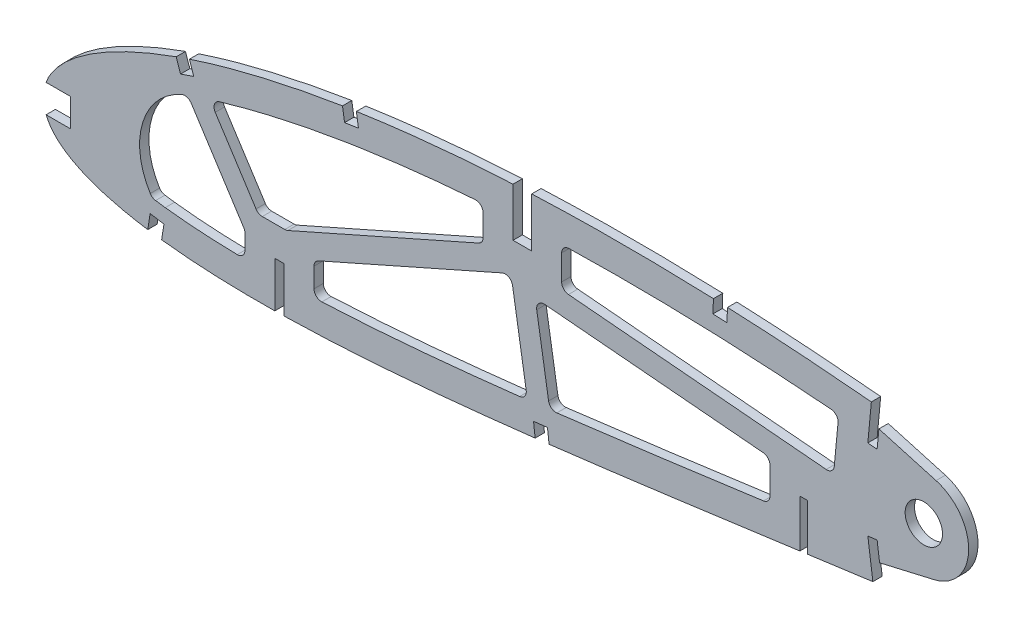
from build123d import *

# Parameters (mm, degrees)
BOSS_EXTRUDE1_DEPTH = 3.175
CUT_EXTRUDE1_DEPTH  = 7.62
SKETCH3_R           = 6.35
CUT_EXTRUDE2_DEPTH  = 7.62
CUT_EXTRUDE3_DEPTH  = 460.680430564
CUT_EXTRUDE4_DEPTH  = 320.461002544
FILLET1_R           = 2.54


with BuildPart() as part:
    # Sketch1 → Boss-Extrude1 (new body)
    with BuildSketch(Plane.XY):
        with BuildLine():
            Line((452.103130844, 0.704841059), (456.093968789, -1.676407199))
            Line((456.093968789, -1.676407199), (451.539257956, -0.704841059))
            add(Edge.make_bspline(
                [(0, 0), (0.116098484, -0.548062271), (0.348829019, -1.646705608), (0.981127511, -3.228296827), (1.817312083, -4.748664111), (2.874932324, -6.203769023), (4.146956076, -7.593213852), (5.630573928, -8.918443806), (7.324330898, -10.17874635), (9.226010202, -11.373547856), (11.332849305, -12.504116729), (13.642480166, -13.569749989), (16.152796843, -14.570114683), (18.861064307, -15.503873502), (21.763971588, -16.372448625), (24.858758771, -17.173723352), (28.141906776, -17.908817596), (31.610257831, -18.575854993), (35.260032504, -19.175513209), (39.087439203, -19.707456616), (43.088549366, -20.172017908), (47.259437594, -20.568222339), (51.595978462, -20.896922095), (56.093849686, -21.158335191), (60.748685259, -21.353290574), (65.556026339, -21.481047186), (70.511164689, -21.543596642), (75.60962225, -21.541878079), (80.846411515, -21.475431763), (86.217059019, -21.347928406), (91.716411041, -21.158560481), (97.339502767, -20.909619435), (103.081262098, -20.60361064), (108.936539298, -20.241571378), (114.900181528, -19.825106256), (120.967010704, -19.35755507), (127.131515672, -18.84008407), (133.388320155, -18.27570942), (139.73188498, -17.667256592), (146.156729407, -17.016651105), (152.657182369, -16.326953548), (159.227454029, -15.600398833), (165.861955098, -14.840863119), (172.554624992, -14.049720613), (179.299804335, -13.231488425), (186.0911476, -12.387729793), (192.922975871, -11.521694689), (199.789144556, -10.637460813), (206.683225759, -9.734927313), (213.599421065, -8.820524357), (220.53106073, -7.893498895), (227.472111233, -6.958618548), (234.416147314, -6.018789286), (241.356405409, -5.07430035), (248.28678484, -4.129065861), (255.200856388, -3.185680808), (262.091847615, -2.244231265), (268.953524037, -1.309396646), (275.778976202, -0.38106275), (282.561910312, 0.538888344), (289.295826346, 1.447710664), (295.974371147, 2.344257157), (302.590655451, 3.227960607), (309.138022785, 4.099152889), (315.511866205, 4.931391047), (321.69553077, 5.768992271), (327.709854245, 6.4556395), (333.649291775, 7.04171769), (339.520012945, 7.522220911), (345.31496828, 7.904062197), (351.027518107, 8.189969928), (356.650854245, 8.383935735), (362.17787359, 8.491713952), (367.601672755, 8.516039607), (372.914848341, 8.464670411), (378.110490176, 8.34174704), (383.181346836, 8.152787103), (388.120344083, 7.904165623), (392.920466429, 7.60266025), (397.574507523, 7.252718477), (402.075982121, 6.8625098), (406.417945063, 6.437746476), (410.593729281, 5.983281443), (414.597241701, 5.508637621), (418.422074216, 5.016940024), (422.062473684, 4.516268978), (425.512580015, 4.011698392), (428.766929364, 3.509669922), (431.820408455, 3.014973074), (434.668085107, 2.534173613), (437.305498365, 2.071763811), (439.728071725, 1.632259415), (441.932444373, 1.221205742), (443.914262697, 0.840644737), (445.670876088, 0.49684807), (447.199018295, 0.19133282), (448.496449148, -0.071596745), (449.560902928, -0.290902855), (450.390762879, -0.462985534), (450.984389878, -0.5881196), (451.34114184, -0.662580877), (451.499651332, -0.696392563), (451.539257956, -0.704841059)],
                knots=[0, 0, 0, 0, 0.003638255, 0.007293231, 0.011028136, 0.014901081, 0.018963272, 0.023258475, 0.027820626, 0.032679082, 0.03785316, 0.043361875, 0.049214679, 0.055422346, 0.061988786, 0.068918036, 0.076211157, 0.083868392, 0.091887411, 0.100265912, 0.108999867, 0.118084529, 0.127514843, 0.13728527, 0.147387917, 0.157816481, 0.168563473, 0.179619128, 0.190977373, 0.202626974, 0.214560478, 0.226767249, 0.239236417, 0.251959004, 0.264923894, 0.278119703, 0.291536035, 0.30516028, 0.318980685, 0.332985499, 0.34716279, 0.361498603, 0.375980747, 0.390597192, 0.405332593, 0.420174823, 0.435109533, 0.450124276, 0.465203068, 0.480333154, 0.495500583, 0.510689775, 0.525887334, 0.541078314, 0.556247233, 0.571381785, 0.58646604, 0.601484515, 0.616424329, 0.631269423, 0.646006524, 0.660620684, 0.675098187, 0.689422858, 0.703581825, 0.716907563, 0.730009274, 0.742952128, 0.755725557, 0.768319951, 0.780724337, 0.792926528, 0.804916041, 0.816679084, 0.828203525, 0.8394749, 0.850481359, 0.861207697, 0.871639326, 0.881763414, 0.891563605, 0.901027365, 0.910138977, 0.918883977, 0.927249278, 0.935221104, 0.942784739, 0.949928188, 0.956638465, 0.962904203, 0.968712288, 0.974054485, 0.978918432, 0.983297219, 0.987180246, 0.990560674, 0.993433357, 0.995790626, 0.997629588, 0.998945816, 0.999736592, 1, 1, 1, 1], degree=3))
            add(Edge.make_bspline(
                [(452.103130844, 0.704841059), (452.068496813, 0.726236426), (451.930095213, 0.811734792), (451.618251437, 1.003015711), (451.098966561, 1.321603382), (450.372013154, 1.765285304), (449.437955605, 2.332883088), (448.296324058, 3.020422222), (446.947831268, 3.825669225), (445.392803438, 4.744815234), (443.631400049, 5.773556989), (441.66429165, 6.907726386), (439.491649667, 8.140902925), (437.114315549, 9.468047233), (434.533105048, 10.882848063), (431.748506266, 12.378914822), (428.761516485, 13.948638114), (425.573282246, 15.58526602), (422.184384898, 17.279761053), (418.59642206, 19.025070833), (414.810589229, 20.812493246), (410.828178709, 22.632492429), (406.65147817, 24.477648573), (402.281642423, 26.336490908), (397.721161703, 28.200965635), (392.971977542, 30.06046153), (388.036901986, 31.906510246), (382.917838926, 33.727152381), (377.618614974, 35.514431666), (372.141800823, 37.256737501), (366.491313143, 38.944607324), (360.670434952, 40.56709799), (354.684018662, 42.115888344), (348.535860801, 43.579699531), (342.231172339, 44.948733274), (335.774964791, 46.214747245), (329.172652762, 47.36510198), (322.442531978, 48.398900537), (315.692888447, 49.25884604), (308.957131835, 50.102255317), (302.231406377, 50.894561333), (295.423478513, 51.653303868), (288.539897863, 52.374211064), (281.587492313, 53.055028822), (274.573300246, 53.692818583), (267.504610588, 54.285710178), (260.388263375, 54.830343915), (253.231762389, 55.325880728), (246.04218283, 55.767964282), (238.827182474, 56.156262652), (231.594085468, 56.488067665), (224.350419046, 56.761093174), (217.103874943, 56.973690929), (209.861975326, 57.123824182), (202.632561324, 57.210549036), (195.423152651, 57.231495803), (188.241586793, 57.186289729), (181.095384018, 57.073378669), (173.992389816, 56.89121691), (166.940134698, 56.63946441), (159.9462446, 56.318230463), (153.018377106, 55.924824851), (146.164047723, 55.461754745), (139.39088931, 54.92707481), (132.706343647, 54.320642895), (126.117416199, 53.644986873), (119.631442696, 52.898268934), (113.255374135, 52.082613865), (106.996184656, 51.199620764), (100.86089724, 50.248808671), (94.856084142, 49.232924024), (88.98822628, 48.153006108), (83.263531815, 47.012221039), (77.688233433, 45.810866329), (72.268232878, 44.552545746), (67.009162956, 43.23945158), (61.916677035, 41.873987713), (56.99593741, 40.459430694), (52.251920045, 38.998989643), (47.690155321, 37.494269359), (43.314090924, 35.950975056), (39.129102409, 34.370202293), (35.138395613, 32.756820932), (31.346647327, 31.113033952), (27.756690145, 29.443852436), (24.372587071, 27.751176724), (21.196749975, 26.039749097), (18.232367129, 24.312193837), (15.482292083, 22.571719722), (12.9476807, 20.82274152), (10.632027491, 19.066357057), (8.536127933, 17.307004609), (6.661308341, 15.547363257), (5.010248609, 13.788645116), (3.582889331, 12.033947283), (2.381101114, 10.284659424), (1.405092396, 8.542436815), (0.657070826, 6.808544998), (0.13629461, 5.083959089), (-0.148774805, 3.371224525), (-0.21973029, 1.668968236), (-0.073133992, 0.555491501), (0, 0)],
                knots=[0, 0, 0, 0, 0.00025409, 0.001015373, 0.002283359, 0.004056577, 0.006330982, 0.009105274, 0.012374489, 0.016134023, 0.02037966, 0.025105976, 0.030306237, 0.035972206, 0.042099522, 0.048678064, 0.055701664, 0.063160184, 0.071045824, 0.079349826, 0.08806291, 0.097175756, 0.106678112, 0.116561573, 0.126814275, 0.137428301, 0.148393618, 0.15969976, 0.171338126, 0.183297699, 0.195569604, 0.208143556, 0.221011593, 0.234161831, 0.24758745, 0.261276822, 0.27522271, 0.289414144, 0.303771199, 0.317689227, 0.331784111, 0.346039677, 0.36044387, 0.37498272, 0.389640454, 0.404403316, 0.419256601, 0.434186749, 0.449177265, 0.464214782, 0.479284009, 0.49436974, 0.509457833, 0.524532346, 0.53957932, 0.554582984, 0.569529546, 0.584403417, 0.599190992, 0.613876838, 0.628447475, 0.642888675, 0.657186054, 0.671325546, 0.685294014, 0.699078147, 0.712665095, 0.726042645, 0.739197713, 0.752117586, 0.764792042, 0.777208152, 0.789355685, 0.80122396, 0.812803686, 0.824082909, 0.835054602, 0.845709571, 0.856037853, 0.866033834, 0.875688843, 0.884997719, 0.893953426, 0.902552897, 0.910789386, 0.918660734, 0.926166253, 0.933302626, 0.94007122, 0.94647478, 0.952517526, 0.958204819, 0.963546652, 0.9685566, 0.973249913, 0.977651041, 0.981787043, 0.985694226, 0.989415109, 0.993001157, 0.996508416, 1, 1, 1, 1], degree=3))
        make_face()
    extrude(amount=BOSS_EXTRUDE1_DEPTH)

    # Sketch2 → Cut-Extrude1 (cut)
    with BuildSketch(Plane(origin=(0, 0, 0), x_dir=(-1, 0, 0), z_dir=(0, 0, -1))):
        Polygon((-81.649081478, -6.010725061), (-78.474081478, -6.010725061), (-78.474081478, -20.922752068), (-78.474081478, -21.704811205), (-81.649081478, -22.486870342), (-81.649081478, -20.922752068), align=None)
        Polygon((-259.449081478, 13.22073836), (-259.449081478, -2.652607086), (-259.449081478, -5.069769756), (-256.909081478, -3.861188421), (-256.909081478, -2.652607086), (-256.909081478, 13.22073836), align=None)
        Polygon((-165.786581478, 56.593547672), (-165.786581478, 39.762876916), (-159.436581478, 39.762876916), (-159.436581478, 56.593547672), (-159.436581478, 57.557196897), (-165.786581478, 58.520846121), align=None)
    extrude(amount=-CUT_EXTRUDE1_DEPTH, mode=Mode.SUBTRACT)

    # Sketch3 → Cut-Extrude2 (cut)
    with BuildSketch(Plane(origin=(0, 0, 0), x_dir=(-1, 0, 0), z_dir=(0, 0, -1))):
        with Locations((-299.038447077, 26.255421435)):
            Circle(SKETCH3_R)
    extrude(amount=-CUT_EXTRUDE2_DEPTH, mode=Mode.SUBTRACT)

    # Sketch4 → Cut-Extrude3 (cut, through all)
    with BuildSketch(Plane.XY.offset(3.175)):
        with BuildLine():
            Line((9.076666365, 6.890948983), (0.724721742, 6.890948983))
            add(Edge.make_bspline(
                [(0.724721742, 6.890948983), (0.709496177, 6.850122056), (0.488246053, 6.249470262), (0.13629461, 5.083959089), (-0.148774805, 3.371224525), (-0.21973029, 1.668968236), (-0.073133992, 0.555491501), (0, 0)],
                knots=[0.985422425, 0.985422425, 0.985422425, 0.985422425, 0.985694226, 0.989415109, 0.993001157, 0.996508416, 1, 1, 1, 1], degree=3))
            add(Edge.make_bspline(
                [(0, 0), (0.116098484, -0.548062271), (0.305939132, -1.444236737), (0.619159788, -2.305351823), (0.755399229, -2.634051017)],
                knots=[0, 0, 0, 0, 0.003638255, 0.005949162, 0.005949162, 0.005949162, 0.005949162], degree=3))
            Line((0.755399229, -2.634051017), (9.076666365, -2.634051017))
            Line((9.076666365, -2.634051017), (9.076666365, 6.890948983))
        make_face()
        with BuildLine():
            Line((50.94528914, 33.718880333), (49.457984223, 38.072533111))
            add(Edge.make_bspline(
                [(49.457984223, 38.072533111), (48.852375707, 37.871291192), (47.347795701, 37.364546546), (45.848492359, 36.842318766), (44.953969582, 36.524088968)],
                knots=[0.862050759, 0.862050759, 0.862050759, 0.862050759, 0.866033834, 0.871959688, 0.871959688, 0.871959688, 0.871959688], degree=3))
            Line((44.953969582, 36.524088968), (46.438686443, 32.179166464))
            Line((46.438686443, 32.179166464), (50.94528914, 33.718880333))
        make_face()
        with BuildLine():
            add(Edge.make_bspline(
                [(35.310795336, -19.167418321), (36.550140988, -19.354805569), (38.11863538, -19.57232394), (39.689829469, -19.768564004), (40.017366507, -19.808559412)],
                knots=[0.092113445, 0.092113445, 0.092113445, 0.092113445, 0.100265912, 0.102412087, 0.102412087, 0.102412087, 0.102412087], degree=3))
            Line((40.017366507, -19.808559412), (40.056230108, -19.559199628))
            Line((40.056230108, -19.559199628), (40.810392071, -14.791064015))
            Line((40.810392071, -14.791064015), (36.113723666, -14.052515981))
            Line((36.113723666, -14.052515981), (35.373024236, -18.771000939))
            Line((35.373024236, -18.771000939), (35.310795336, -19.167418321))
        make_face()
        with BuildLine():
            Line((39.567645247, -22.694097363), (40.017366507, -19.808559412))
            add(Edge.make_bspline(
                [(35.310795336, -19.167418321), (36.550140988, -19.354805569), (38.11863538, -19.57232394), (39.689829469, -19.768564004), (40.017366507, -19.808559412)],
                knots=[0.092113445, 0.092113445, 0.092113445, 0.092113445, 0.100265912, 0.102412087, 0.102412087, 0.102412087, 0.102412087], degree=3))
            Line((35.310795336, -19.167418321), (34.872872851, -21.957120289))
            Line((34.872872851, -21.957120289), (39.567645247, -22.694097363))
        make_face()
        with BuildLine():
            Line((106.90066319, 46.481463728), (106.209861612, 51.068186439))
            add(Edge.make_bspline(
                [(106.209861612, 51.068186439), (104.629351245, 50.831477167), (103.050077247, 50.586505601), (101.472164136, 50.333054309)],
                knots=[0.740777655, 0.740777655, 0.740777655, 0.740777655, 0.750752382, 0.750752382, 0.750752382, 0.750752382], degree=3))
            Line((101.472164136, 50.333054309), (102.191303266, 45.7721599))
            Line((102.191303266, 45.7721599), (106.90066319, 46.481463728))
        make_face()
        with BuildLine():
            add(Edge.make_bspline(
                [(166.948991926, -14.709918965), (168.528216327, -14.525231657), (170.10720639, -14.338540702), (171.685988187, -14.15010551)],
                knots=[0.378399329, 0.378399329, 0.378399329, 0.378399329, 0.388741043, 0.388741043, 0.388741043, 0.388741043], degree=3))
            Line((171.685988187, -14.15010551), (171.13396989, -9.48059682))
            Line((171.13396989, -9.48059682), (166.404404763, -10.039712392))
            Line((166.404404763, -10.039712392), (166.948991926, -14.709918965))
        make_face()
        with BuildLine():
            Line((232.119167537, 51.839052458), (232.321761642, 56.447492051))
            add(Edge.make_bspline(
                [(232.321761642, 56.447492051), (232.079950316, 56.457793824), (230.485264408, 56.525079676), (228.890398482, 56.588062732), (227.537258876, 56.638361271)],
                knots=[0.477773375, 0.477773375, 0.477773375, 0.477773375, 0.479284009, 0.48773546, 0.48773546, 0.48773546, 0.48773546], degree=3))
            Line((227.537258876, 56.638361271), (227.36106217, 52.037340067))
            Line((227.36106217, 52.037340067), (232.119167537, 51.839052458))
        make_face()
        with BuildLine():
            Line((280.002959876, 40.404001741), (283.163447077, 40.103220767))
            Line((283.163447077, 40.103220767), (283.772153107, 46.420883565))
            Line((283.772153107, 46.420883565), (284.380859136, 52.738546364))
            Line((284.380859136, 52.738546364), (284.384742546, 52.778851653))
            add(Edge.make_bspline(
                [(284.384742546, 52.778851653), (283.458514825, 52.868893345), (282.400140093, 52.970319768), (281.341607713, 53.07007766), (281.209561744, 53.0824957)],
                knots=[0.369174414, 0.369174414, 0.369174414, 0.369174414, 0.37498272, 0.375810522, 0.375810522, 0.375810522, 0.375810522], degree=3))
            Line((281.209561744, 53.0824957), (281.206083771, 53.045950544))
            Line((281.206083771, 53.045950544), (280.002959876, 40.404001741))
        make_face()
        with BuildLine():
            add(Edge.make_bspline(
                [(284.384742546, 52.778851653), (283.458514825, 52.868893345), (282.400140093, 52.970319768), (281.341607713, 53.07007766), (281.209561744, 53.0824957)],
                knots=[0.369174414, 0.369174414, 0.369174414, 0.369174414, 0.37498272, 0.375810522, 0.375810522, 0.375810522, 0.375810522], degree=3))
            Line((284.384742546, 52.778851653), (284.770272262, 56.780203084))
            Line((284.770272262, 56.780203084), (281.590271339, 57.082841163))
            Line((281.590271339, 57.082841163), (281.209561744, 53.0824957))
        make_face()
        with BuildLine():
            Line((284.380859136, 52.738546364), (283.772153107, 46.420883565))
            Line((283.772153107, 46.420883565), (303.192982236, 40.918212356))
            ThreePointArc((303.192982236, 40.918212356), (311.195188331, 35.446245233), (314.278447077, 26.255421435))
            ThreePointArc((314.278447077, 26.255421435), (310.969793045, 16.773829618), (302.480470254, 11.409207222))
            Line((302.480470254, 11.409207222), (284.012930322, 7.127597139))
            Line((284.012930322, 7.127597139), (284.860476862, 0.848860649))
            add(Edge.make_bspline(
                [(284.860476862, 0.848860649), (286.34516108, 1.049390117), (290.056592049, 1.549837975), (295.974371147, 2.344257157), (302.590655451, 3.227960607), (309.138022785, 4.099152889), (315.511866205, 4.931391047), (321.69553077, 5.768992271), (327.709854245, 6.4556395), (333.649291775, 7.04171769), (339.520012945, 7.522220911), (345.31496828, 7.904062197), (351.027518107, 8.189969928), (356.650854245, 8.383935735), (362.17787359, 8.491713952), (367.601672755, 8.516039607), (372.914848341, 8.464670411), (378.110490176, 8.34174704), (383.181346836, 8.152787103), (388.120344083, 7.904165623), (392.920466429, 7.60266025), (397.574507523, 7.252718477), (402.075982121, 6.8625098), (406.417945063, 6.437746476), (410.593729281, 5.983281443), (414.597241701, 5.508637621), (418.422074216, 5.016940024), (422.062473684, 4.516268978), (425.512580015, 4.011698392), (428.766929364, 3.509669922), (431.820408455, 3.014973074), (434.668085107, 2.534173613), (437.305498365, 2.071763811), (439.728071725, 1.632259415), (441.932444373, 1.221205742), (443.914262697, 0.840644737), (445.670876088, 0.49684807), (447.199018295, 0.19133282), (448.496449148, -0.071596745), (449.560902928, -0.290902855), (450.390762879, -0.462985534), (450.984389878, -0.5881196), (451.34114184, -0.662580877), (451.499651332, -0.696392563), (451.539257956, -0.704841059)],
                knots=[0.63626204, 0.63626204, 0.63626204, 0.63626204, 0.646006524, 0.660620684, 0.675098187, 0.689422858, 0.703581825, 0.716907563, 0.730009274, 0.742952128, 0.755725557, 0.768319951, 0.780724337, 0.792926528, 0.804916041, 0.816679084, 0.828203525, 0.8394749, 0.850481359, 0.861207697, 0.871639326, 0.881763414, 0.891563605, 0.901027365, 0.910138977, 0.918883977, 0.927249278, 0.935221104, 0.942784739, 0.949928188, 0.956638465, 0.962904203, 0.968712288, 0.974054485, 0.978918432, 0.983297219, 0.987180246, 0.990560674, 0.993433357, 0.995790626, 0.997629588, 0.998945816, 0.999736592, 1, 1, 1, 1], degree=3))
            Line((451.539257956, -0.704841059), (456.093968789, -1.676407199))
            Line((456.093968789, -1.676407199), (452.103130844, 0.704841059))
            add(Edge.make_bspline(
                [(452.103130844, 0.704841059), (452.068496813, 0.726236426), (451.930095213, 0.811734792), (451.618251437, 1.003015711), (451.098966561, 1.321603382), (450.372013154, 1.765285304), (449.437955605, 2.332883088), (448.296324058, 3.020422222), (446.947831268, 3.825669225), (445.392803438, 4.744815234), (443.631400049, 5.773556989), (441.66429165, 6.907726386), (439.491649667, 8.140902925), (437.114315549, 9.468047233), (434.533105048, 10.882848063), (431.748506266, 12.378914822), (428.761516485, 13.948638114), (425.573282246, 15.58526602), (422.184384898, 17.279761053), (418.59642206, 19.025070833), (414.810589229, 20.812493246), (410.828178709, 22.632492429), (406.65147817, 24.477648573), (402.281642423, 26.336490908), (397.721161703, 28.200965635), (392.971977542, 30.06046153), (388.036901986, 31.906510246), (382.917838926, 33.727152381), (377.618614974, 35.514431666), (372.141800823, 37.256737501), (366.491313143, 38.944607324), (360.670434952, 40.56709799), (354.684018662, 42.115888344), (348.535860801, 43.579699531), (342.231172339, 44.948733274), (335.774964791, 46.214747245), (329.172652762, 47.36510198), (322.442531978, 48.398900537), (315.692888447, 49.25884604), (308.957131835, 50.102255317), (302.231406377, 50.894561333), (295.423478513, 51.653303868), (289.603246246, 52.262848164), (286.052736483, 52.616099696), (284.798474131, 52.738546364)],
                knots=[0, 0, 0, 0, 0.00025409, 0.001015373, 0.002283359, 0.004056577, 0.006330982, 0.009105274, 0.012374489, 0.016134023, 0.02037966, 0.025105976, 0.030306237, 0.035972206, 0.042099522, 0.048678064, 0.055701664, 0.063160184, 0.071045824, 0.079349826, 0.08806291, 0.097175756, 0.106678112, 0.116561573, 0.126814275, 0.137428301, 0.148393618, 0.15969976, 0.171338126, 0.183297699, 0.195569604, 0.208143556, 0.221011593, 0.234161831, 0.24758745, 0.261276822, 0.27522271, 0.289414144, 0.303771199, 0.317689227, 0.331784111, 0.346039677, 0.36044387, 0.368309569, 0.368309569, 0.368309569, 0.368309569], degree=3))
            Line((284.798474131, 52.738546364), (284.380859136, 52.738546364))
        make_face()
        with BuildLine():
            Line((284.860476862, 0.848860649), (284.012930322, 7.127597139))
            Line((284.012930322, 7.127597139), (283.163447077, 13.420680993))
            Line((283.163447077, 13.420680993), (280.017033521, 12.995599475))
            Line((280.017033521, 12.995599475), (281.715516034, 0.4235911))
            add(Edge.make_bspline(
                [(281.715516034, 0.4235911), (282.003163555, 0.462531675), (283.051468053, 0.604404862), (284.099794103, 0.746118727), (284.860476862, 0.848860649)],
                knots=[0.629381417, 0.629381417, 0.629381417, 0.629381417, 0.631269423, 0.63626204, 0.63626204, 0.63626204, 0.63626204], degree=3))
        make_face()
        with BuildLine():
            Line((284.862413567, 0.834513285), (284.860476862, 0.848860649))
            add(Edge.make_bspline(
                [(281.715516034, 0.4235911), (282.003163555, 0.462531675), (283.051468053, 0.604404862), (284.099794103, 0.746118727), (284.860476862, 0.848860649)],
                knots=[0.629381417, 0.629381417, 0.629381417, 0.629381417, 0.631269423, 0.63626204, 0.63626204, 0.63626204, 0.63626204], degree=3))
            Line((281.715516034, 0.4235911), (281.717359592, 0.40994525))
            Line((281.717359592, 0.40994525), (282.089214043, -2.34248654))
            Line((282.089214043, -2.34248654), (285.235627599, -1.917405022))
            Line((285.235627599, -1.917405022), (284.862413567, 0.834513285))
        make_face()
        with BuildLine():
            Line((466.088227074, 52.738546364), (284.798474131, 52.738546364))
            add(Edge.make_bspline(
                [(452.103130844, 0.704841059), (452.068496813, 0.726236426), (451.930095213, 0.811734792), (451.618251437, 1.003015711), (451.098966561, 1.321603382), (450.372013154, 1.765285304), (449.437955605, 2.332883088), (448.296324058, 3.020422222), (446.947831268, 3.825669225), (445.392803438, 4.744815234), (443.631400049, 5.773556989), (441.66429165, 6.907726386), (439.491649667, 8.140902925), (437.114315549, 9.468047233), (434.533105048, 10.882848063), (431.748506266, 12.378914822), (428.761516485, 13.948638114), (425.573282246, 15.58526602), (422.184384898, 17.279761053), (418.59642206, 19.025070833), (414.810589229, 20.812493246), (410.828178709, 22.632492429), (406.65147817, 24.477648573), (402.281642423, 26.336490908), (397.721161703, 28.200965635), (392.971977542, 30.06046153), (388.036901986, 31.906510246), (382.917838926, 33.727152381), (377.618614974, 35.514431666), (372.141800823, 37.256737501), (366.491313143, 38.944607324), (360.670434952, 40.56709799), (354.684018662, 42.115888344), (348.535860801, 43.579699531), (342.231172339, 44.948733274), (335.774964791, 46.214747245), (329.172652762, 47.36510198), (322.442531978, 48.398900537), (315.692888447, 49.25884604), (308.957131835, 50.102255317), (302.231406377, 50.894561333), (295.423478513, 51.653303868), (289.603246246, 52.262848164), (286.052736483, 52.616099696), (284.798474131, 52.738546364)],
                knots=[0, 0, 0, 0, 0.00025409, 0.001015373, 0.002283359, 0.004056577, 0.006330982, 0.009105274, 0.012374489, 0.016134023, 0.02037966, 0.025105976, 0.030306237, 0.035972206, 0.042099522, 0.048678064, 0.055701664, 0.063160184, 0.071045824, 0.079349826, 0.08806291, 0.097175756, 0.106678112, 0.116561573, 0.126814275, 0.137428301, 0.148393618, 0.15969976, 0.171338126, 0.183297699, 0.195569604, 0.208143556, 0.221011593, 0.234161831, 0.24758745, 0.261276822, 0.27522271, 0.289414144, 0.303771199, 0.317689227, 0.331784111, 0.346039677, 0.36044387, 0.368309569, 0.368309569, 0.368309569, 0.368309569], degree=3))
            Line((452.103130844, 0.704841059), (456.093968789, -1.676407199))
            Line((456.093968789, -1.676407199), (451.539257956, -0.704841059))
            add(Edge.make_bspline(
                [(284.860476862, 0.848860649), (286.34516108, 1.049390117), (290.056592049, 1.549837975), (295.974371147, 2.344257157), (302.590655451, 3.227960607), (309.138022785, 4.099152889), (315.511866205, 4.931391047), (321.69553077, 5.768992271), (327.709854245, 6.4556395), (333.649291775, 7.04171769), (339.520012945, 7.522220911), (345.31496828, 7.904062197), (351.027518107, 8.189969928), (356.650854245, 8.383935735), (362.17787359, 8.491713952), (367.601672755, 8.516039607), (372.914848341, 8.464670411), (378.110490176, 8.34174704), (383.181346836, 8.152787103), (388.120344083, 7.904165623), (392.920466429, 7.60266025), (397.574507523, 7.252718477), (402.075982121, 6.8625098), (406.417945063, 6.437746476), (410.593729281, 5.983281443), (414.597241701, 5.508637621), (418.422074216, 5.016940024), (422.062473684, 4.516268978), (425.512580015, 4.011698392), (428.766929364, 3.509669922), (431.820408455, 3.014973074), (434.668085107, 2.534173613), (437.305498365, 2.071763811), (439.728071725, 1.632259415), (441.932444373, 1.221205742), (443.914262697, 0.840644737), (445.670876088, 0.49684807), (447.199018295, 0.19133282), (448.496449148, -0.071596745), (449.560902928, -0.290902855), (450.390762879, -0.462985534), (450.984389878, -0.5881196), (451.34114184, -0.662580877), (451.499651332, -0.696392563), (451.539257956, -0.704841059)],
                knots=[0.63626204, 0.63626204, 0.63626204, 0.63626204, 0.646006524, 0.660620684, 0.675098187, 0.689422858, 0.703581825, 0.716907563, 0.730009274, 0.742952128, 0.755725557, 0.768319951, 0.780724337, 0.792926528, 0.804916041, 0.816679084, 0.828203525, 0.8394749, 0.850481359, 0.861207697, 0.871639326, 0.881763414, 0.891563605, 0.901027365, 0.910138977, 0.918883977, 0.927249278, 0.935221104, 0.942784739, 0.949928188, 0.956638465, 0.962904203, 0.968712288, 0.974054485, 0.978918432, 0.983297219, 0.987180246, 0.990560674, 0.993433357, 0.995790626, 0.997629588, 0.998945816, 0.999736592, 1, 1, 1, 1], degree=3))
            Line((284.860476862, 0.848860649), (284.862413567, 0.834513285))
            Line((284.862413567, 0.834513285), (466.088227074, -18.771000939))
            Line((466.088227074, -18.771000939), (466.088227074, 52.738546364))
        make_face()
    extrude(amount=-CUT_EXTRUDE3_DEPTH, mode=Mode.SUBTRACT)


with BuildPart() as body_2:
    # of the pieces the cut leaves, the one that is kept (cut_extrude3_keep)
    add(part.part.solids().sort_by_distance((232.321761642, 56.447492051, 0))[0])

    # Sketch5 → Cut-Extrude4 (cut, through all)
    with BuildSketch(Plane.XY.offset(3.175)):
        with BuildLine():
            ThreePointArc((48.359351671, 26.951786589), (33.662203419, 11.770011742), (36.829708633, -9.121598175))
            Line((36.829708633, -9.121598175), (41.248852551, -9.723469322))
            add(Edge.make_bspline(
                [(41.248852551, -9.723469322), (42.758212792, -9.907776656), (45.773395172, -10.235170642), (51.885654424, -10.756253149), (59.392149246, -11.170006324), (65.403526556, -11.316703139), (68.314081478, -11.35226521)],
                knots=[0.102412087, 0.102412087, 0.102412087, 0.102412087, 0.112851931, 0.123291776, 0.144171465, 0.163633402, 0.163633402, 0.163633402, 0.163633402], degree=3))
            Line((68.314081478, -11.35226521), (68.314081478, -2.882836135))
            Line((68.314081478, -2.882836135), (48.95119544, 27.155252438))
            Line((48.95119544, 27.155252438), (48.359351671, 26.951786589))
        make_face()
        with BuildLine():
            add(Edge.make_bspline(
                [(103.083454258, 40.301636456), (98.788403433, 39.611746642), (90.207213091, 38.101001537), (77.48510802, 35.41602737), (66.200354481, 32.571445305), (59.244941197, 30.530333734), (56.413940314, 29.642347547)],
                knots=[0.750752382, 0.750752382, 0.750752382, 0.750752382, 0.778576976, 0.80640157, 0.834226165, 0.853510778, 0.853510778, 0.853510778, 0.853510778], degree=3))
            Line((56.413940314, 29.642347547), (72.847058502, 4.149274939))
            Line((72.847058502, 4.149274939), (82.401104828, 4.149274939))
            Line((82.401104828, 4.149274939), (149.276581478, 33.769873793))
            Line((149.276581478, 33.769873793), (149.276581478, 45.48497375))
            add(Edge.make_bspline(
                [(149.276581478, 45.48497375), (148.461117807, 45.428450057), (143.271542371, 45.058169004), (133.728966045, 44.251429069), (120.679613621, 42.834488458), (112.032064191, 41.666849619), (107.714716991, 41.020250816)],
                knots=[0.652108864, 0.652108864, 0.652108864, 0.652108864, 0.657294996, 0.685122549, 0.712950102, 0.740777655, 0.740777655, 0.740777655, 0.740777655], degree=3))
            Line((107.714716991, 41.020250816), (103.083454258, 40.301636456))
        make_face()
        with BuildLine():
            Line((91.809081478, -0.017721939), (91.809081478, -10.977698198))
            add(Edge.make_bspline(
                [(91.809081478, -10.977698198), (91.850327892, -10.976039425), (95.390285769, -10.833286487), (105.951840754, -10.308151251), (123.515780864, -9.024316581), (144.151759364, -7.057111175), (157.773900506, -5.548051388), (164.337760971, -4.785503394)],
                knots=[0.215739949, 0.215739949, 0.215739949, 0.215739949, 0.216013438, 0.239211423, 0.285607391, 0.33200336, 0.375255674, 0.375255674, 0.375255674, 0.375255674], degree=3))
            Line((164.337760971, -4.785503394), (159.274675479, 26.383054007))
            ThreePointArc((159.274675479, 26.383054007), (157.977256776, 28.209213241), (155.738900793, 28.298181403))
            Line((155.738900793, 28.298181403), (91.809081478, -0.017721939))
        make_face()
        with BuildLine():
            Line((166.964589936, 26.567532329), (171.912257584, -3.890508193))
            add(Edge.make_bspline(
                [(171.912257584, -3.890508193), (172.031456971, -3.87620172), (178.634640162, -3.083129685), (192.315737028, -1.376017631), (212.977606558, 1.33427113), (231.319479133, 3.811506342), (242.581976085, 5.346312296), (246.749081478, 5.914913989)],
                knots=[0.391878822, 0.391878822, 0.391878822, 0.391878822, 0.392663266, 0.435331542, 0.48192204, 0.528512539, 0.555874043, 0.555874043, 0.555874043, 0.555874043], degree=3))
            Line((246.749081478, 5.914913989), (246.749081478, 19.556054472))
            Line((246.749081478, 19.556054472), (166.964589936, 26.567532329))
        make_face()
        with BuildLine():
            Line((175.946581478, 46.772554587), (175.946581478, 33.427560804))
            Line((175.946581478, 33.427560804), (268.36021076, 25.306231673))
            Line((268.36021076, 25.306231673), (270.12671756, 43.867984628))
            add(Edge.make_bspline(
                [(270.12671756, 43.867984628), (269.4767603, 43.922421238), (264.798006642, 44.309607109), (256.087087446, 44.967519612), (243.99082279, 45.725542729), (235.924202525, 46.124803088), (231.889312262, 46.296699593)],
                knots=[0.397188572, 0.397188572, 0.397188572, 0.397188572, 0.401301235, 0.426791948, 0.452282662, 0.477773375, 0.477773375, 0.477773375, 0.477773375], degree=3))
            Line((231.889312262, 46.296699593), (227.159854742, 46.485373232))
            add(Edge.make_bspline(
                [(227.159854742, 46.485373232), (222.077474167, 46.674294108), (211.906455154, 46.962763366), (196.660669325, 47.11161023), (184.673133046, 46.99252014), (177.773582226, 46.824267278), (175.946581478, 46.772554587)],
                knots=[0.48773546, 0.48773546, 0.48773546, 0.48773546, 0.519861968, 0.551988475, 0.584114983, 0.595689911, 0.595689911, 0.595689911, 0.595689911], degree=3))
        make_face()
    extrude(amount=-CUT_EXTRUDE4_DEPTH, mode=Mode.SUBTRACT)

    # Fillet1
    fillet1_edges = [body_2.edges().sort_by_distance(p)[0] for p in [
        (270.12671756, 43.867984628, 1.5875),
        (268.36021076, 25.306231673, 1.5875),
        (246.749081478, 5.914913989, 1.5875),
        (246.749081478, 19.556054472, 1.5875),
        (171.912257584, -3.890508193, 1.5875),
        (164.337760971, -4.785503394, 1.5875),
        (166.964589936, 26.567532329, 1.5875),
        (175.946581478, 46.772554587, 1.5875),
        (175.946581478, 33.427560804, 1.5875),
        (149.276581478, 45.48497375, 1.5875),
        (149.276581478, 33.769873793, 1.5875),
        (91.809081478, -10.977698198, 1.5875),
        (91.809081478, -0.017721939, 1.5875),
        (68.314081478, -2.882836135, 1.5875),
        (68.314081478, -11.35226521, 1.5875),
        (82.401104828, 4.149274939, 1.5875),
        (72.847058502, 4.149274939, 1.5875),
        (56.413940314, 29.642347547, 1.5875),
        (48.95119544, 27.155252438, 1.5875),
        (36.829708633, -9.121598175, 1.5875),
    ]]
    fillet(fillet1_edges, radius=FILLET1_R)


solid = body_2.part
